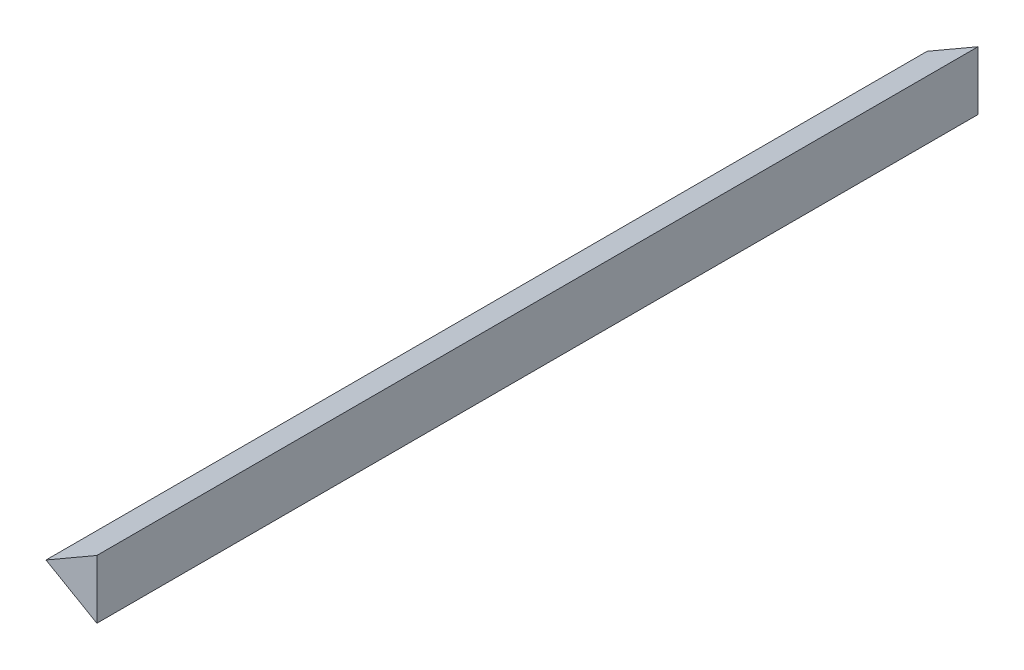
from build123d import *

# Parameters (mm, degrees)
BOSS_EXTRUDE1_DEPTH = 600


with BuildPart() as part:
    # Sketch1 → Boss-Extrude1 (new body)
    with BuildSketch(Plane.XY):
        Polygon((120, 140), (154.641016151, 160), (154.641016151, 120), align=None)
    extrude(amount=-BOSS_EXTRUDE1_DEPTH)


solid = part.part
